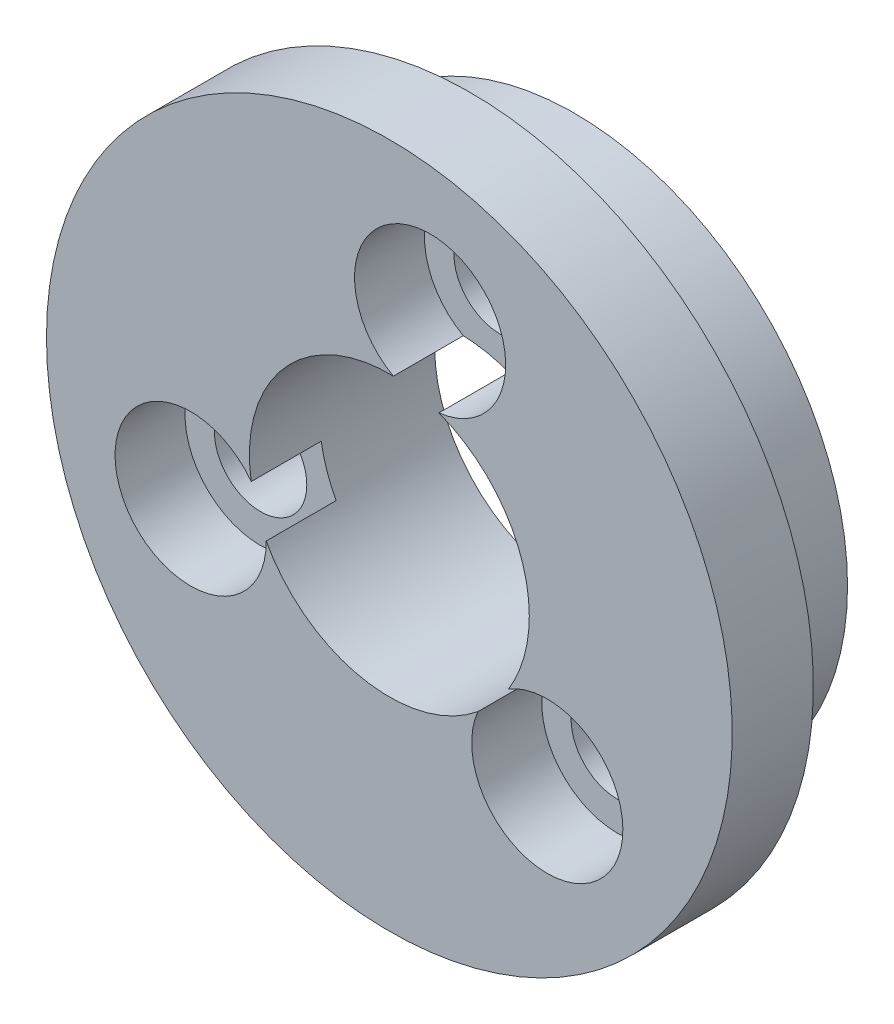
from build123d import *

# Parameters (mm, degrees)
SKETCH1_R           = 12.25
BOSS_EXTRUDE1_DEPTH = 2.9
CUT_EXTRUDE1_REACH  = 364.631
SKETCH2_R           = 5
CUT_EXTRUDE2_REACH  = 364.631
SKETCH5_R           = 1.65
SKETCH6_R           = 9.75
SKETCH6_R_2         = 5
BOSS_EXTRUDE2_DEPTH = 3.72
SKETCH7_R           = 1.65
CUT_EXTRUDE3_DEPTH  = 3.72
SKETCH8_R           = 2.7
CUT_EXTRUDE4_DEPTH  = 2.5


with BuildPart() as part:
    # Sketch1 → Boss-Extrude1 (new body)
    with BuildSketch(Plane.XY):
        with Locations(Location((350.15, -0.367507575, 0), (0, 0, 180))):
            Circle(SKETCH1_R)
    extrude(amount=BOSS_EXTRUDE1_DEPTH)

    # Sketch2 → Cut-Extrude1 (cut, up to next)
    with BuildSketch(Plane.XY.offset(2.9), mode=Mode.PRIVATE) as cut_extrude1_sk1:
        with Locations((350.15, -0.367507575)):
            Circle(SKETCH2_R)
    cut_extrude1_tool1 = extrude(cut_extrude1_sk1.sketch, amount=-CUT_EXTRUDE1_REACH, mode=Mode.PRIVATE) & part.part
    add(cut_extrude1_tool1.solids().sort_by_distance((350.15, -0.367508, 2.9))[0], mode=Mode.SUBTRACT)

    # Sketch5 → Cut-Extrude2 (cut, up to next)
    with BuildSketch(Plane.XY.offset(2.9), mode=Mode.PRIVATE) as cut_extrude2_sk1:
        with Locations((343.05020627, -2.784722708)):
            Circle(SKETCH5_R)
    cut_extrude2_tool1 = extrude(cut_extrude2_sk1.sketch, amount=-CUT_EXTRUDE2_REACH, mode=Mode.PRIVATE) & part.part
    # Sketch5 → Cut-Extrude2 (cut, up to next)
    with BuildSketch(Plane.XY.offset(2.9), mode=Mode.PRIVATE) as cut_extrude2_sk2:
        with Locations((355.793266576, -5.30750174)):
            Circle(SKETCH5_R)
    cut_extrude2_tool2 = extrude(cut_extrude2_sk2.sketch, amount=-CUT_EXTRUDE2_REACH, mode=Mode.PRIVATE) & part.part
    # Sketch5 → Cut-Extrude2 (cut, up to next)
    with BuildSketch(Plane.XY.offset(2.9), mode=Mode.PRIVATE) as cut_extrude2_sk3:
        with Locations((351.606527153, 6.989701723)):
            Circle(SKETCH5_R)
    cut_extrude2_tool3 = extrude(cut_extrude2_sk3.sketch, amount=-CUT_EXTRUDE2_REACH, mode=Mode.PRIVATE) & part.part
    add(cut_extrude2_tool1.solids().sort_by_distance((343.050206, -2.784723, 2.9))[0], mode=Mode.SUBTRACT)
    add(cut_extrude2_tool2.solids().sort_by_distance((355.793267, -5.307502, 2.9))[0], mode=Mode.SUBTRACT)
    add(cut_extrude2_tool3.solids().sort_by_distance((351.606527, 6.989702, 2.9))[0], mode=Mode.SUBTRACT)

    # Sketch6 → Boss-Extrude2 (add)
    with BuildSketch(Plane(origin=(0, 0, 0), x_dir=(-1, 0, 0), z_dir=(0, 0, -1))):
        with Locations(Location((-350.15, -0.367507575, 0), (0, 0, 180))):
            Circle(SKETCH6_R)
        with Locations(Location((-350.15, -0.367507575, 0), (0, 0, 180))):
            Circle(SKETCH6_R_2, mode=Mode.SUBTRACT)
    extrude(amount=BOSS_EXTRUDE2_DEPTH)

    # Sketch7 → Cut-Extrude3 (cut)
    with BuildSketch(Plane.XY):
        with Locations((351.606527153, 6.989701723)):
            Circle(SKETCH7_R)
        with Locations((343.05020627, -2.784722708)):
            Circle(SKETCH7_R)
        with Locations((355.793266576, -5.30750174)):
            Circle(SKETCH7_R)
    extrude(amount=-CUT_EXTRUDE3_DEPTH, mode=Mode.SUBTRACT)

    # Sketch8 → Cut-Extrude4 (cut)
    with BuildSketch(Plane.XY.offset(2.9)):
        with Locations((351.606527153, 6.989701723)):
            Circle(SKETCH8_R)
        with Locations((355.793266576, -5.30750174)):
            Circle(SKETCH8_R)
        with Locations((343.05020627, -2.784722708)):
            Circle(SKETCH8_R)
    extrude(amount=-CUT_EXTRUDE4_DEPTH, mode=Mode.SUBTRACT)


solid = part.part
